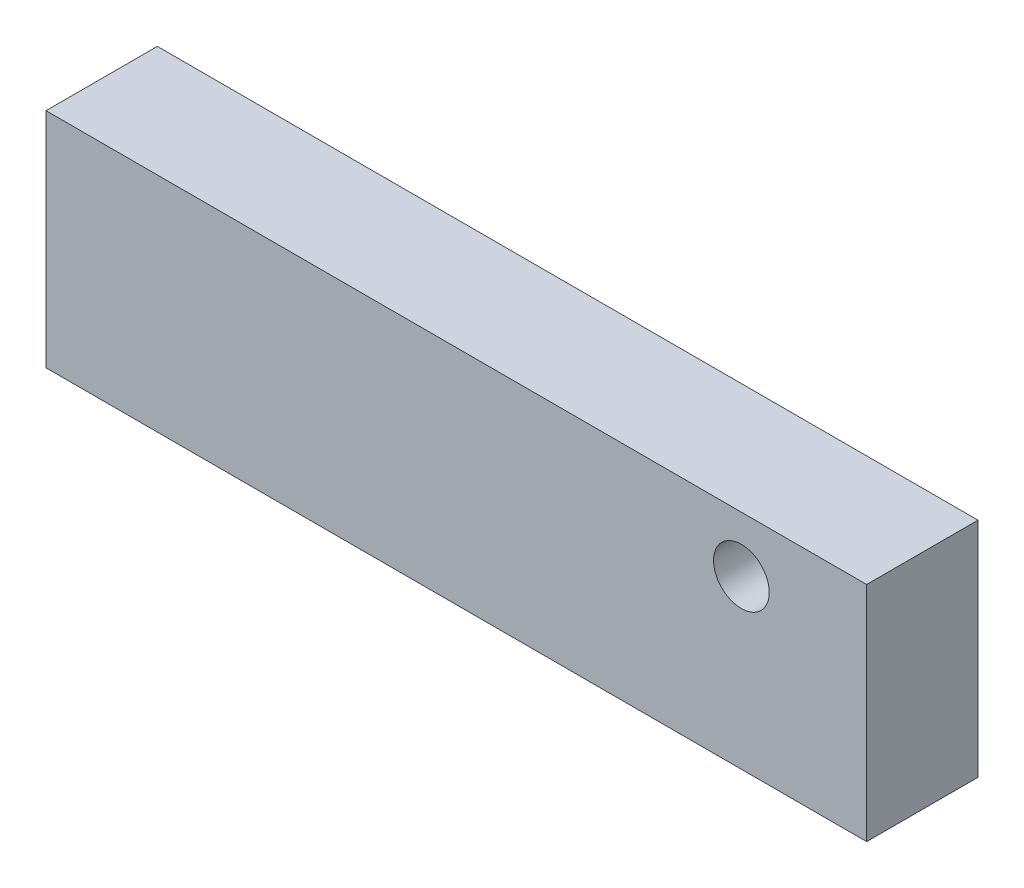
from build123d import *

# Parameters (mm, degrees)
SKETCH1_W           = 187.198
SKETCH1_H           = 50.8
BOSS_EXTRUDE1_DEPTH = 25.4
SKETCH3_R           = 6.35
CUT_EXTRUDE2_DEPTH  = 254


with BuildPart() as part:
    # Sketch1 → Boss-Extrude1 (new body)
    with BuildSketch(Plane.XY):
        with Locations((93.599, 25.4)):
            Rectangle(SKETCH1_W, SKETCH1_H)
    extrude(amount=BOSS_EXTRUDE1_DEPTH)

    # Sketch3 → Cut-Extrude2 (cut)
    with BuildSketch(Plane.XY.offset(25.4)):
        with Locations((158.623, 38.1)):
            Circle(SKETCH3_R)
    extrude(amount=-CUT_EXTRUDE2_DEPTH, mode=Mode.SUBTRACT)


solid = part.part
